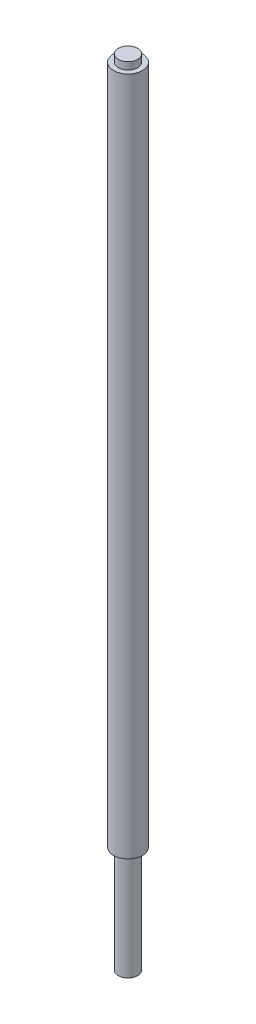
from build123d import *

# Parameters (mm, degrees)
SKETCH1_R           = 4
BOSS_EXTRUDE1_DEPTH = 329.2
SKETCH2_R           = 6
BOSS_EXTRUDE2_DEPTH = 282
SKETCH4_R           = 5
SKETCH4_R_2         = 4
CUT_EXTRUDE1_DEPTH  = 30


with BuildPart() as part:
    # Sketch1 → Boss-Extrude1 (new body)
    with BuildSketch(Plane(origin=(0, 0, 0), x_dir=(1, 0, 0), z_dir=(0, 1, 0))):
        Circle(SKETCH1_R)
    extrude(amount=BOSS_EXTRUDE1_DEPTH)

    # Sketch2 → Boss-Extrude2 (add)
    with BuildSketch(Plane(origin=(0, 326.2, 0), x_dir=(1, 0, 0), z_dir=(0, 1, 0))):
        Circle(SKETCH2_R)
    extrude(amount=-BOSS_EXTRUDE2_DEPTH)

    # Sketch4 → Cut-Extrude1 (cut)
    with BuildSketch(Plane(origin=(0, 289.2, 0), x_dir=(1, 0, 0), z_dir=(0, 1, 0))):
        Circle(SKETCH4_R)
        Circle(SKETCH4_R_2, mode=Mode.SUBTRACT)
    extrude(amount=-CUT_EXTRUDE1_DEPTH, mode=Mode.SUBTRACT)


solid = part.part
